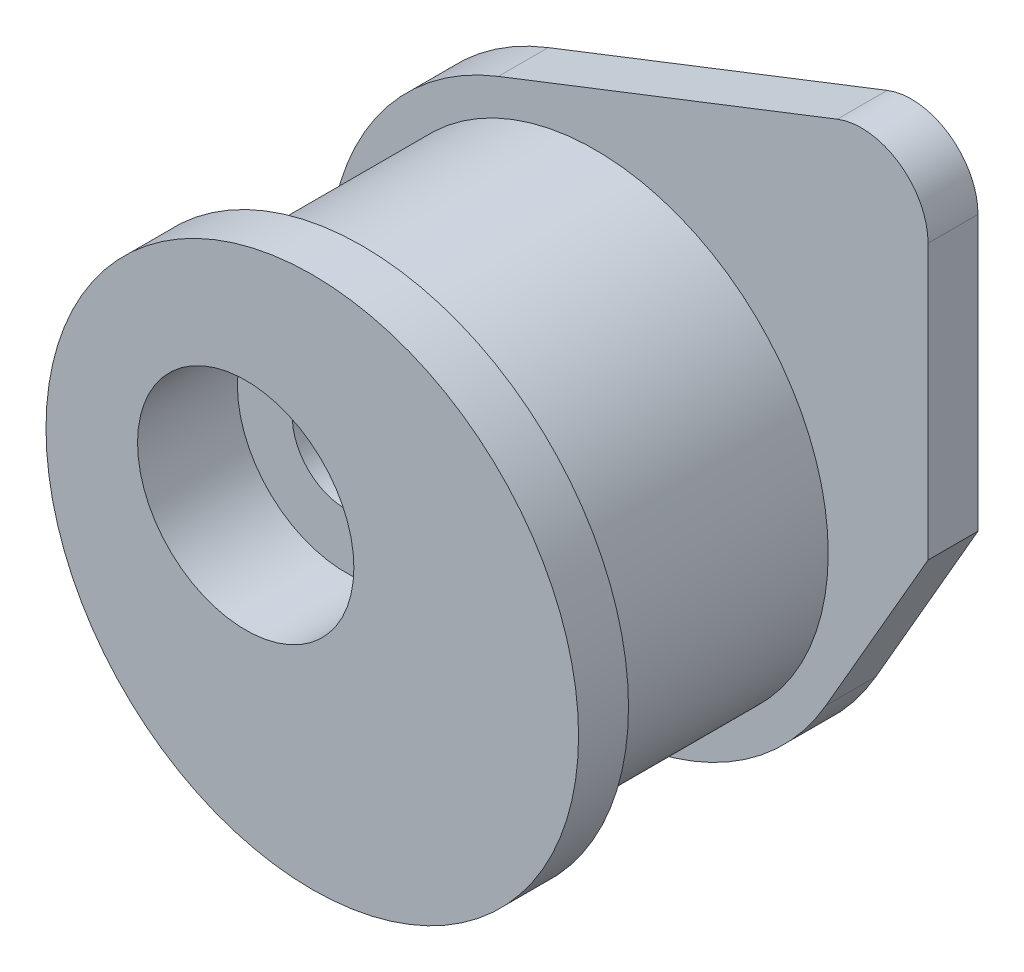
from build123d import *

# Parameters (mm, degrees)
SKETCH1_R           = 8
SKETCH1_R_2         = 1.6
BOSS_EXTRUDE1_DEPTH = 10
SKETCH2_R           = 3.25
CUT_EXTRUDE1_DEPTH  = 3
SKETCH3_W           = 6.504954041
SKETCH3_H           = 7
BOSS_EXTRUDE2_DEPTH = 1.5
FILLET1_R           = 2


with BuildPart() as part:
    # Sketch1 → Boss-Extrude1 (new body)
    with BuildSketch(Plane.XY):
        with Locations((2, -1)):
            Circle(SKETCH1_R)
        Circle(SKETCH1_R_2, mode=Mode.SUBTRACT)
    extrude(amount=BOSS_EXTRUDE1_DEPTH)

    # Sketch2 → Cut-Extrude1 (cut)
    with BuildSketch(Plane.XY.offset(10)):
        Circle(SKETCH2_R)
    extrude(amount=-CUT_EXTRUDE1_DEPTH, mode=Mode.SUBTRACT)

    # Sketch3 → Cut-Revolve1 (revolve, cut)
    with BuildSketch(Plane(origin=(0, -1, 0), x_dir=(1, 0, 0), z_dir=(0, 1, 0))):
        with Locations((-8.252477021, -5)):
            Rectangle(SKETCH3_W, SKETCH3_H)
    revolve(axis=Axis((2, -1, 0), (0, 0, 1)), mode=Mode.SUBTRACT)

    # Sketch4 → Boss-Extrude2 (add)
    with BuildSketch(Plane.XY):
        with BuildLine():
            Line((-0.911080318, 6.451550938), (12, 11.49549308))
            Line((12, 11.49549308), (12, 0.324258737))
            Line((12, 0.324258737), (8.929423504, -4.997885679))
            ThreePointArc((8.929423504, -4.997885679), (8.06705614, 4.214482697), (-0.911080318, 6.451550938))
        make_face()
    extrude(amount=BOSS_EXTRUDE2_DEPTH)

    # Fillet1
    fillet1_edges = [part.edges().sort_by_distance(p)[0] for p in [
        (12, 11.49549308, 0.75),
    ]]
    fillet(fillet1_edges, radius=FILLET1_R)


solid = part.part
